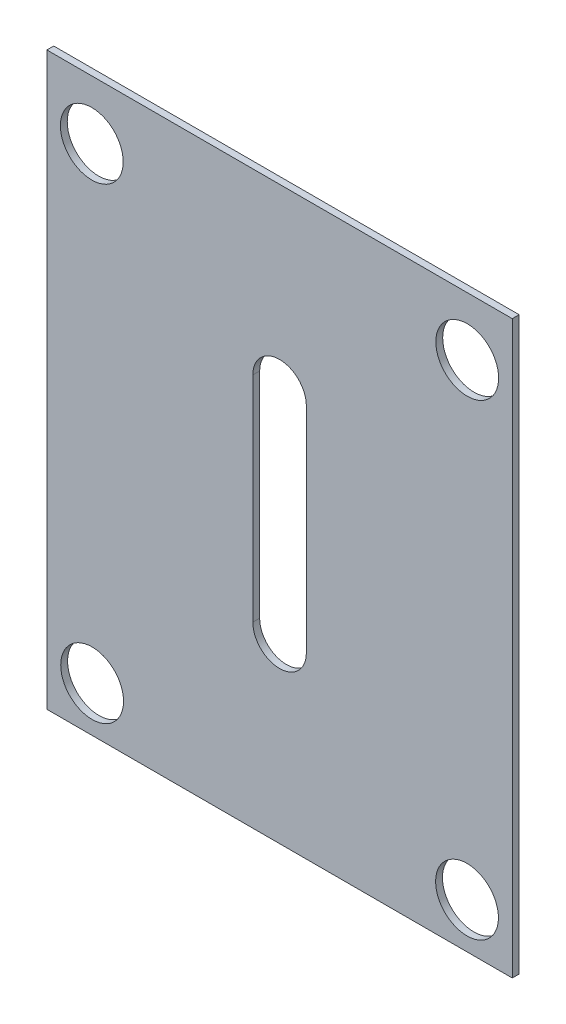
from build123d import *

# Parameters (mm, degrees)
SKETCH1_W           = 41.4
SKETCH1_H           = 50.8
BOSS_EXTRUDE1_DEPTH = 0.6096
CUT_EXTRUDE2_DEPTH  = 0.6096
SKETCH9_R           = 2.794
CUT_EXTRUDE3_DEPTH  = 0.6096


with BuildPart() as part:
    # Sketch1 → Boss-Extrude1 (new body)
    with BuildSketch(Plane.XY):
        with Locations((-4635.961935484, -4371.258064516)):
            Rectangle(SKETCH1_W, SKETCH1_H)
    extrude(amount=BOSS_EXTRUDE1_DEPTH)

    # Sketch4 → Cut-Extrude2 (cut)
    with BuildSketch(Plane.XY.offset(0.6096)):
        with BuildLine():
            Line((-4638.343185484, -4380.783064516), (-4638.343185484, -4361.733064516))
            ThreePointArc((-4638.343185484, -4361.733064516), (-4635.961935484, -4359.351814516), (-4633.580685484, -4361.733064516))
            Line((-4633.580685484, -4361.733064516), (-4633.580685484, -4380.783064516))
            ThreePointArc((-4633.580685484, -4380.783064516), (-4635.961935484, -4383.164314516), (-4638.343185484, -4380.783064516))
        make_face()
    extrude(amount=-CUT_EXTRUDE2_DEPTH, mode=Mode.SUBTRACT)

    # Sketch9 → Cut-Extrude3 (cut)
    with BuildSketch(Plane(origin=(0, 0, 0), x_dir=(-1, 0, 0), z_dir=(0, 0, -1))):
        with Locations((4619.267234292, -4351.044101977)):
            Circle(SKETCH9_R)
        with Locations((4652.667204287, -4351.088871634)):
            Circle(SKETCH9_R)
        with Locations((4619.28588452, -4392.63411548)):
            Circle(SKETCH9_R)
        with Locations((4652.637986448, -4392.63411548)):
            Circle(SKETCH9_R)
    extrude(amount=-CUT_EXTRUDE3_DEPTH, mode=Mode.SUBTRACT)


solid = part.part
